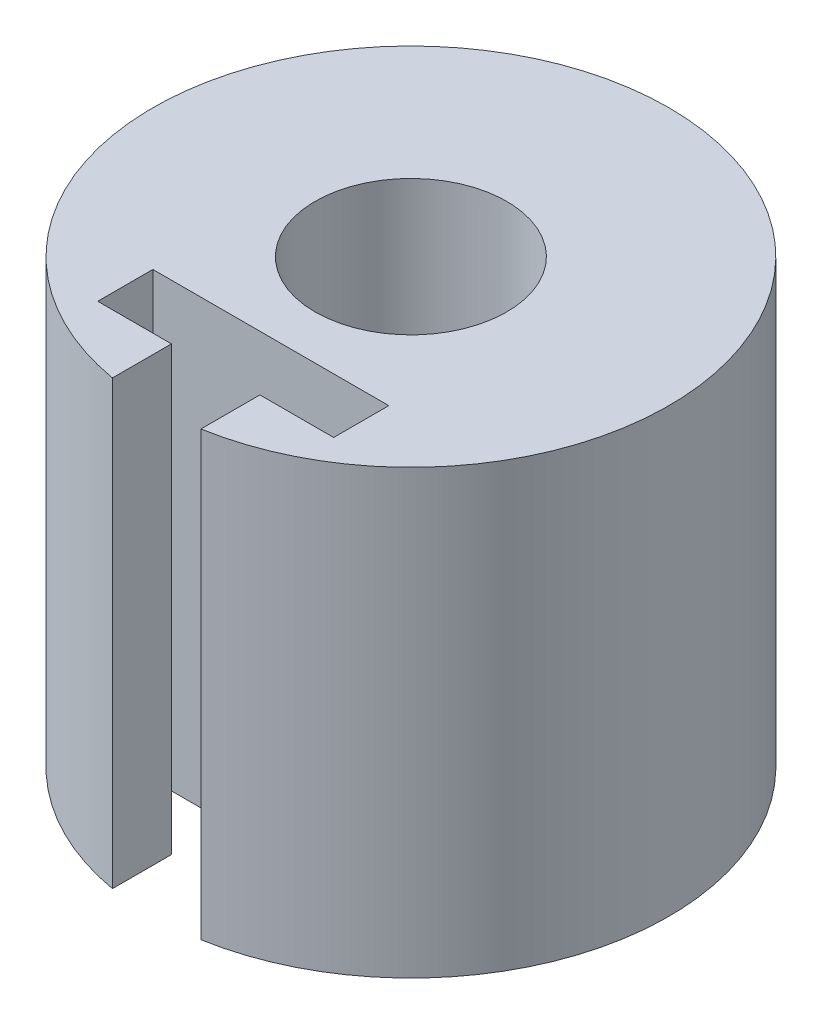
from build123d import *

# Parameters (mm, degrees)
SKETCH1_R           = 8.75
SKETCH1_R_2         = 3.25
BOSS_EXTRUDE1_DEPTH = 15
SKETCH2_W           = 3
SKETCH2_H           = 15
CUT_EXTRUDE2_DEPTH  = 4
SKETCH3_R           = 1.25
CUT_EXTRUDE3_DEPTH  = 8
SKETCH5_W           = 1.870469825
SKETCH5_H           = 15
CUT_EXTRUDE4_DEPTH  = 4


with BuildPart() as part:
    # Sketch1 → Boss-Extrude1 (new body)
    with BuildSketch(Plane(origin=(0, 0, 0), x_dir=(1, 0, 0), z_dir=(0, 1, 0))):
        Circle(SKETCH1_R)
        Circle(SKETCH1_R_2, mode=Mode.SUBTRACT)
    extrude(amount=BOSS_EXTRUDE1_DEPTH)

    # Sketch2 → Cut-Extrude2 (cut)
    with BuildSketch(Plane.XY.offset(8.75)):
        with Locations((0, 7.5)):
            Rectangle(SKETCH2_W, SKETCH2_H)
    extrude(amount=-CUT_EXTRUDE2_DEPTH, mode=Mode.SUBTRACT)

    # Sketch3 → Cut-Extrude3 (cut)
    with BuildSketch(Plane(origin=(0, 0, -8.75), x_dir=(-1, 0, 0), z_dir=(0, 0, -1))):
        with Locations((0, 7.5)):
            Circle(SKETCH3_R)
    extrude(amount=-CUT_EXTRUDE3_DEPTH, mode=Mode.SUBTRACT)

    # Sketch5 → Cut-Extrude4 (cut, symmetric)
    with BuildSketch(Plane.ZY):
        with Locations((5.685234913, 7.5)):
            Rectangle(SKETCH5_W, SKETCH5_H)
    extrude(amount=CUT_EXTRUDE4_DEPTH, both=True, mode=Mode.SUBTRACT)


solid = part.part
